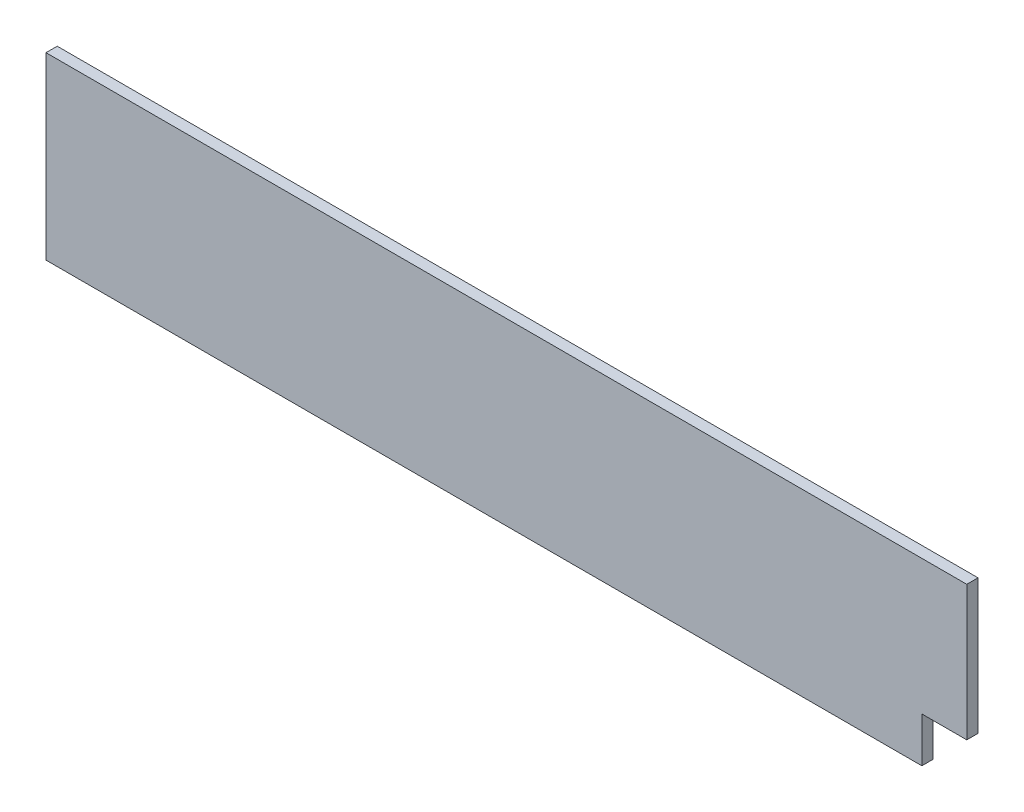
from build123d import *

# Parameters (mm, degrees)
ESBO_O1_W                = 2050
ESBO_O1_H                = 400
RESSALTO_EXTRUS_O1_DEPTH = 25
ESBO_O3_W                = 100
ESBO_O3_H                = 100
CORTE_EXTRUS_O2_DEPTH    = 25


with BuildPart() as part:
    # Esboço1 → Ressalto-extrusão1 (new body)
    with BuildSketch(Plane.XY):
        with Locations((1025, 200)):
            Rectangle(ESBO_O1_W, ESBO_O1_H)
    extrude(amount=RESSALTO_EXTRUS_O1_DEPTH)

    # Esboço3 → Corte-extrusão2 (cut)
    with BuildSketch(Plane.XY.offset(25)):
        with Locations((2000, 50)):
            Rectangle(ESBO_O3_W, ESBO_O3_H)
    extrude(amount=-CORTE_EXTRUS_O2_DEPTH, mode=Mode.SUBTRACT)


solid = part.part
